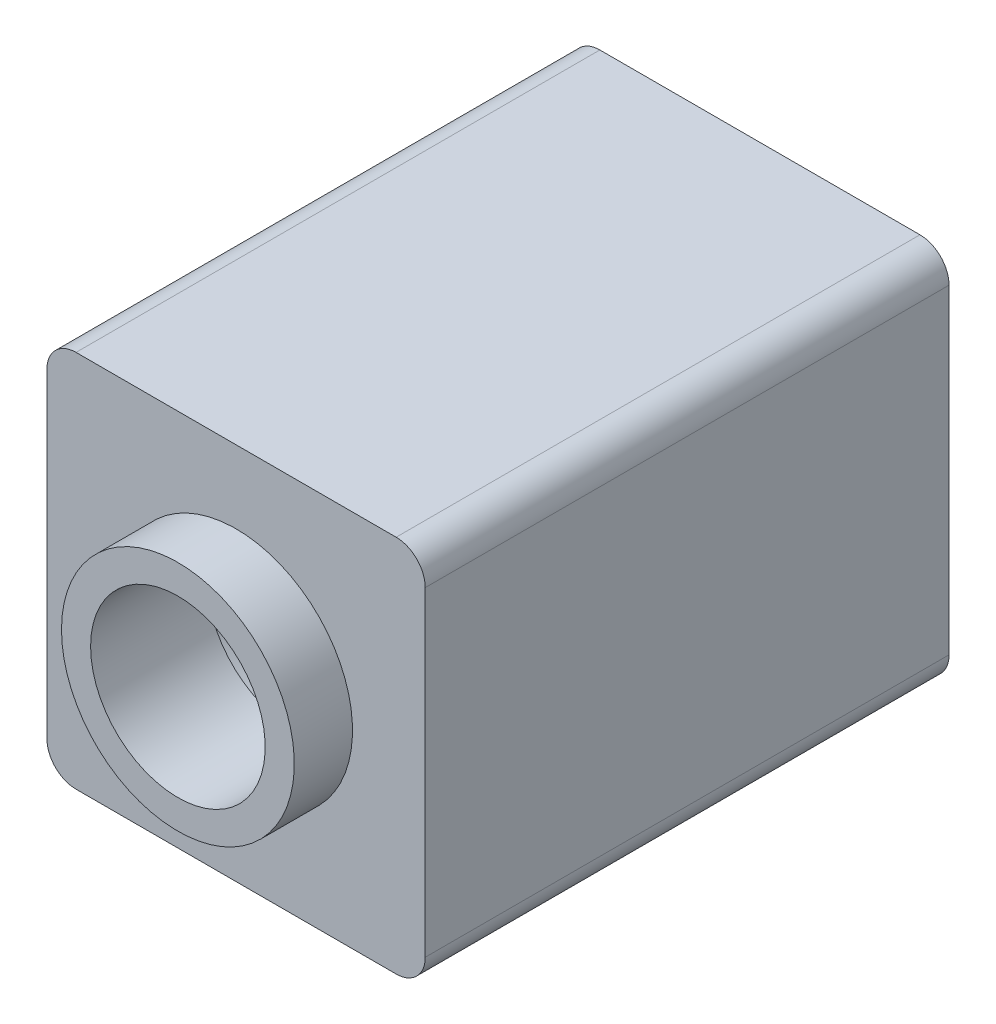
from build123d import *

# Parameters (mm, degrees)
SKETCH2_R           = 1.5
BOSS_EXTRUDE1_DEPTH = 10
SKETCH3_R           = 2
CUT_EXTRUDE1_DEPTH  = 1
SKETCH4_R           = 2.4
CUT_EXTRUDE2_DEPTH  = 8


with BuildPart() as part:
    # Sketch2 → Boss-Extrude1 (new body)
    with BuildSketch(Plane(origin=(0, 0, -57.465471353), x_dir=(-1, 0, 0), z_dir=(0, 0, -1))):
        with BuildLine():
            Line((-6.490457264, -35.078386779), (-0.990457264, -35.078386779))
            ThreePointArc((-0.990457264, -35.078386779), (-0.636903873, -34.931940169), (-0.490457264, -34.578386779))
            Line((-0.490457264, -34.578386779), (-0.490457264, -29.078386779))
            ThreePointArc((-0.490457264, -29.078386779), (-0.636903873, -28.724833388), (-0.990457264, -28.578386779))
            Line((-0.990457264, -28.578386779), (-6.490457264, -28.578386779))
            ThreePointArc((-6.490457264, -28.578386779), (-6.844010654, -28.724833388), (-6.990457264, -29.078386779))
            Line((-6.990457264, -29.078386779), (-6.990457264, -34.578386779))
            ThreePointArc((-6.990457264, -34.578386779), (-6.844010654, -34.931940169), (-6.490457264, -35.078386779))
        make_face()
        with Locations((-3.740457264, -31.828386779)):
            Circle(SKETCH2_R, mode=Mode.SUBTRACT)
    extrude(amount=BOSS_EXTRUDE1_DEPTH)

    # Sketch3 → Cut-Extrude1 (cut)
    with BuildSketch(Plane(origin=(0, 0, -57.465471353), x_dir=(-1, 0, 0), z_dir=(0, 0, -1))):
        with BuildLine():
            Line((-0.990457264, -28.578386779), (-6.490457264, -28.578386779))
            ThreePointArc((-6.490457264, -28.578386779), (-6.844010654, -28.724833388), (-6.990457264, -29.078386779))
            Line((-6.990457264, -29.078386779), (-6.990457264, -34.578386779))
            ThreePointArc((-6.990457264, -34.578386779), (-6.844010654, -34.931940169), (-6.490457264, -35.078386779))
            Line((-6.490457264, -35.078386779), (-0.990457264, -35.078386779))
            ThreePointArc((-0.990457264, -35.078386779), (-0.636903873, -34.931940169), (-0.490457264, -34.578386779))
            Line((-0.490457264, -34.578386779), (-0.490457264, -29.078386779))
            ThreePointArc((-0.490457264, -29.078386779), (-0.636903873, -28.724833388), (-0.990457264, -28.578386779))
        make_face()
        with Locations((-3.740457264, -31.828386779)):
            Circle(SKETCH3_R, mode=Mode.SUBTRACT)
    extrude(amount=CUT_EXTRUDE1_DEPTH, mode=Mode.SUBTRACT)

    # Sketch4 → Cut-Extrude2 (cut)
    with BuildSketch(Plane(origin=(0, 0, -67.465471353), x_dir=(-1, 0, 0), z_dir=(0, 0, -1))):
        with Locations((-3.740457264, -31.828386779)):
            Circle(SKETCH4_R)
    extrude(amount=-CUT_EXTRUDE2_DEPTH, mode=Mode.SUBTRACT)


solid = part.part
